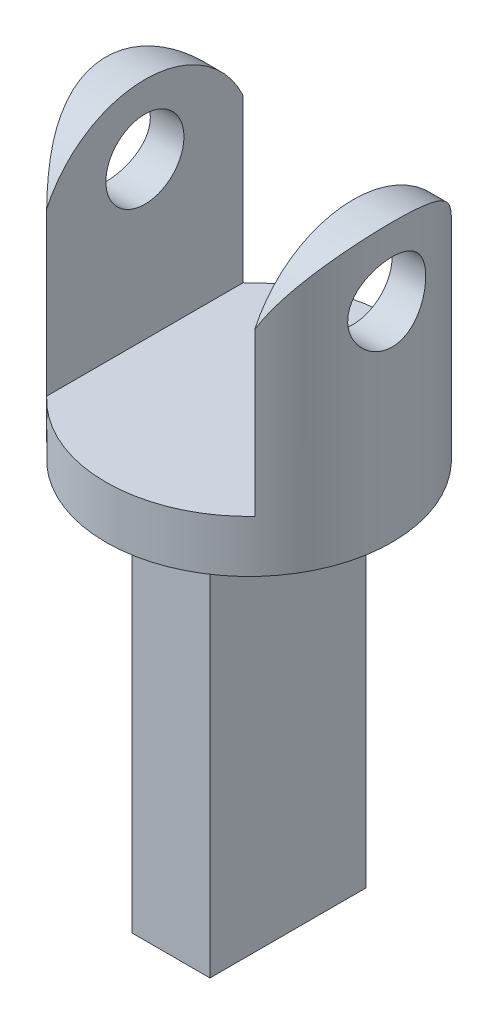
from build123d import *

# Parameters (mm, degrees)
SKETCH_1_R          = 5.5
EXTRUDE_1_DEPTH     = 26
SKETCH_2_W          = 8
SKETCH_2_H          = 18
CUT_EXTRUDE_1_DEPTH = 25
SKETCH_3_R          = 1.5
CUT_EXTRUDE_2_DEPTH = 25
CUT_EXTRUDE_3_DEPTH = 11
SKETCH_6_W          = 25.84971197
SKETCH_6_H          = 26.022962568
SKETCH_6_W_2        = 3
SKETCH_6_H_2        = 6
CUT_EXTRUDE_4_DEPTH = 15


with BuildPart() as part:
    # 草图1 → 凸台-拉伸1 (new body)
    with BuildSketch(Plane(origin=(0, 0, 0), x_dir=(1, 0, 0), z_dir=(0, 1, 0))):
        Circle(SKETCH_1_R)
    extrude(amount=EXTRUDE_1_DEPTH)

    # 草图2 → 切除-拉伸1 (cut, symmetric)
    with BuildSketch(Plane.XY):
        with Locations((0, 26)):
            Rectangle(SKETCH_2_W, SKETCH_2_H)
    extrude(amount=CUT_EXTRUDE_1_DEPTH, both=True, mode=Mode.SUBTRACT)

    # 草图3 → 切除-拉伸2 (cut, symmetric)
    with BuildSketch(Plane(origin=(-4, 0, 0), x_dir=(0, 0, -1), z_dir=(1, 0, 0))):
        with Locations((0, 23)):
            Circle(SKETCH_3_R)
    extrude(amount=CUT_EXTRUDE_2_DEPTH, both=True, mode=Mode.SUBTRACT)

    # 草图5 → 切除-拉伸3 (cut, symmetric)
    with BuildSketch(Plane(origin=(0, 0, 0), x_dir=(0, 0, -1), z_dir=(1, 0, 0))):
        with BuildLine():
            Line((-4.153311931, 21.5), (-12.215121886, 24.91830584))
            Line((-12.215121886, 24.91830584), (0.629850505, 32.78071868))
            Line((0.629850505, 32.78071868), (12.991410006, 24.598657791))
            Line((12.991410006, 24.598657791), (4.153311931, 21.5))
            ThreePointArc((4.153311931, 21.5), (0, 25.653311931), (-4.153311931, 21.5))
        make_face()
    extrude(amount=CUT_EXTRUDE_3_DEPTH, both=True, mode=Mode.SUBTRACT)

    # 草图6 → 切除-拉伸4 (cut)
    with BuildSketch(Plane(origin=(0, 0, 0), x_dir=(-1, 0, 0), z_dir=(0, -1, 0))):
        Rectangle(SKETCH_6_W, SKETCH_6_H)
        Rectangle(SKETCH_6_W_2, SKETCH_6_H_2, mode=Mode.SUBTRACT)
    extrude(amount=-CUT_EXTRUDE_4_DEPTH, mode=Mode.SUBTRACT)


solid = part.part
